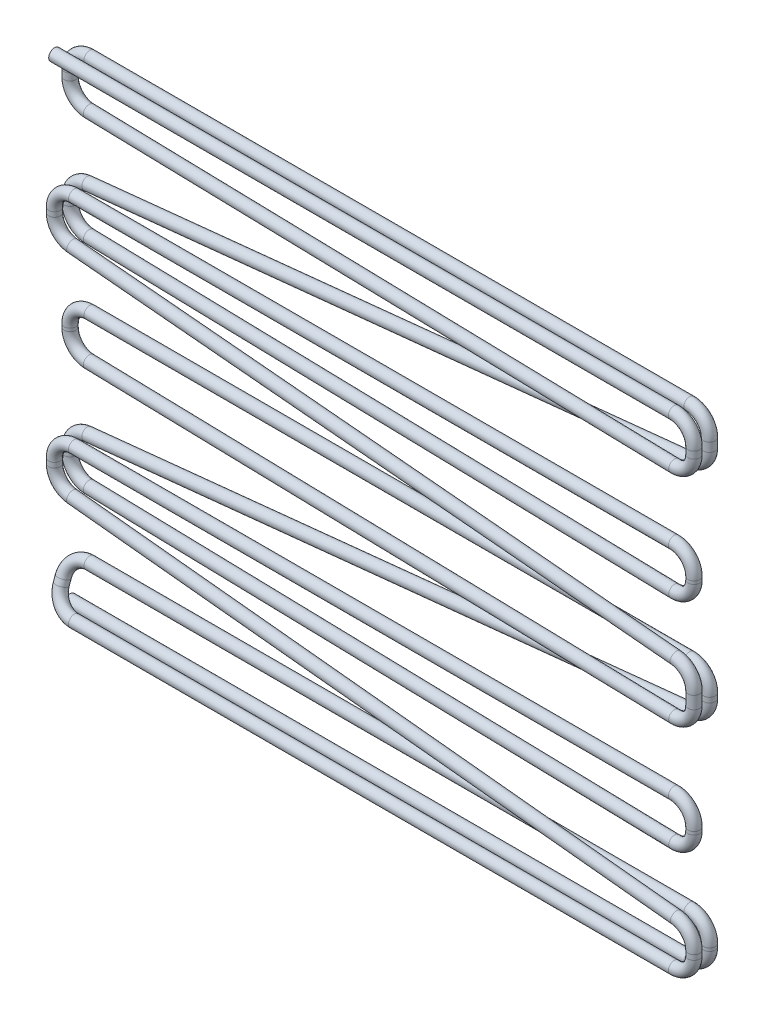
from build123d import *

# Parameters (mm, degrees)
SKETCH5_R = 0.3


with BuildPart() as part:
    # Sweep4: sweep along a curve in space
    with BuildLine() as sweep4_path:
        Line((-33, 0, 0), (-1.021255708, 0, 0))
        ThreePointArc((-1.021255708, 0, 0), (-0.299118872, 0.299118872, 0), (0, 1.021255708, 0))
        Line((0, 1.021255708, 0), (0, 1.178744292, 0))
        ThreePointArc((-1.021255708, 2.2, 0), (-0.299118872, 1.900881128, 0), (0, 1.178744292, 0))
        Line((-1.021255708, 2.2, 0), (-31.978744292, 2.2, 0))
        ThreePointArc((-31.978744292, 2.2, 0), (-32.700881128, 1.918890052, 0.102221799), (-33, 1.240230602, 0.349007054))
        Line((-33, 1.240230602, 0.349007054), (-33, 0.959769398, 0.450992946))
        ThreePointArc((-33, 0.959769398, 0.450992946), (-32.700881128, 0.281109948, 0.6977782), (-31.978744292, 0, 0.8))
        Line((-31.978744292, 0, 0.8), (-1.021255708, 0, 0.8))
        ThreePointArc((-1.021255708, 0, 0.8), (-0.299118872, 0.299118872, 0.8), (0, 1.021255708, 0.8))
        Line((0, 1.021255708, 0.8), (0, 1.278558447, 0.8))
        ThreePointArc((0, 1.278558447, 0.8), (-0.263016234, 1.962690102, 0.8), (-0.916589485, 2.294436492, 0.8))
        Line((-0.916589485, 2.294436492, 0.8), (-32.083410515, 5.505563508, 0.8))
        ThreePointArc((-33, 6.521441553, 0.8), (-32.736983766, 5.837309898, 0.8), (-32.083410515, 5.505563508, 0.8))
        Line((-33, 6.778744292, 0.8), (-33, 6.521441553, 0.8))
        ThreePointArc((-31.978744292, 7.8, 0.8), (-32.700881128, 7.500881128, 0.8), (-33, 6.778744292, 0.8))
        Line((-31.978744292, 7.8, 0.8), (-1.021255708, 7.8, 0.8))
        ThreePointArc((0, 6.778744292, 0.8), (-0.299118872, 7.500881128, 0.8), (-1.021255708, 7.8, 0.8))
        Line((0, 6.778744292, 0.8), (0, 6.621255708, 0.8))
        ThreePointArc((-1.020955747, 5.6, 0.775249557), (-0.299031015, 5.899118872, 0.792750763), (0, 6.621255708, 0.8))
        Line((-1.020955747, 5.6, 0.775249557), (-31.979044253, 5.6, 0.024750442))
        ThreePointArc((-33, 6.621255708, 0), (-32.700968985, 5.899118872, 0.007249237), (-31.979044253, 5.6, 0.024750442))
        Line((-33, 6.621255708, 0), (-33, 6.878558447, 0))
        ThreePointArc((-33, 6.878558447, 0), (-32.736983766, 7.562690102, 0), (-32.083410515, 7.894436492, 0))
        Line((-32.083410515, 7.894436492, 0), (-0.916589485, 11.105563508, 0))
        ThreePointArc((0, 12.121441553, 0), (-0.263016234, 11.437309898, 0), (-0.916589485, 11.105563508, 0))
        Line((0, 12.378744292, 0), (0, 12.121441553, 0))
        ThreePointArc((0, 12.378744292, 0), (-0.299118872, 13.100881128, 0), (-1.021255708, 13.4, 0))
        Line((-1.021255708, 13.4, 0), (-31.978744292, 13.4, 0))
        ThreePointArc((-31.978744292, 13.4, 0), (-32.700881128, 13.100881128, 0), (-33, 12.378744292, 0))
        Line((-33, 12.221255708, 0), (-33, 12.378744292, 0))
        ThreePointArc((-33, 12.221255708, 0), (-32.700968985, 11.499118872, 0.007249237), (-31.979044253, 11.2, 0.024750442))
        Line((-31.979044253, 11.2, 0.024750442), (-1.020955747, 11.2, 0.775249558))
        ThreePointArc((-1.020955747, 11.2, 0.775249558), (-0.299031015, 11.499118872, 0.792750763), (0, 12.221255708, 0.8))
        Line((0, 12.221255708, 0.8), (0, 12.867374339, 0.8))
        ThreePointArc((-0.92879556, 13.88443596, 0.8), (-0.267137456, 13.556046164, 0.8), (0, 12.867374339, 0.8))
        Line((-0.92879556, 13.88443596, 0.8), (-32.07120444, 16.71556404, 0.8))
        ThreePointArc((-32.07120444, 16.71556404, 0.8), (-32.732862544, 17.043953836, 0.8), (-33, 17.732625661, 0.8))
        Line((-33, 17.978744292, 0.8), (-33, 17.732625661, 0.8))
        ThreePointArc((-31.978744292, 19, 0.8), (-32.700881128, 18.700881128, 0.8), (-33, 17.978744292, 0.8))
        Line((-1.021255708, 19, 0.8), (-31.978744292, 19, 0.8))
        ThreePointArc((0, 17.978744292, 0.8), (-0.299118872, 18.700881128, 0.8), (-1.021255708, 19, 0.8))
        Line((0, 17.821255708, 0.8), (0, 17.978744292, 0.8))
        ThreePointArc((0, 17.821255708, 0.8), (-0.299031015, 17.099118872, 0.792750763), (-1.020955747, 16.8, 0.775249558))
        Line((-1.020955747, 16.8, 0.775249558), (-31.979044253, 16.8, 0.024750442))
        ThreePointArc((-33, 17.821255708, 0), (-32.700968985, 17.099118872, 0.007249237), (-31.979044253, 16.8, 0.024750442))
        Line((-33, 17.821255708, 0), (-33, 18.078558447, 0))
        ThreePointArc((-32.083410515, 19.094436492, 0), (-32.736983766, 18.762690102, 0), (-33, 18.078558447, 0))
        Line((-32.083410515, 19.094436492, 0), (-0.916589485, 22.305563508, 0))
        ThreePointArc((0, 23.321441553, 0), (-0.263016234, 22.637309898, 0), (-0.916589485, 22.305563508, 0))
        Line((0, 23.778744292, 0), (0, 23.321441553, 0))
        ThreePointArc((-1.021255708, 24.8, 0), (-0.299118872, 24.500881128, 0), (0, 23.778744292, 0))
        Line((-31.978744292, 24.8, 0), (-1.021255708, 24.8, 0))
        ThreePointArc((-31.978744292, 24.8, 0), (-32.700881128, 24.500881128, 0), (-33, 23.778744292, 0))
        Line((-33, 23.421255708, 0), (-33, 23.778744292, 0))
        ThreePointArc((-33, 23.421255708, 0), (-32.700968985, 22.699118872, 0.007249237), (-31.979044253, 22.4, 0.024750442))
        Line((-31.979044253, 22.4, 0.024750442), (-1.020955747, 22.4, 0.775249558))
        ThreePointArc((-1.020955747, 22.4, 0.775249558), (-0.299031015, 22.699118872, 0.792750763), (0, 23.421255708, 0.8))
        Line((0, 23.421255708, 0.8), (0, 23.778744292, 0.8))
        ThreePointArc((0, 23.778744292, 0.8), (-0.299118872, 24.500881128, 0.8), (-1.021255708, 24.8, 0.8))
        Line((-1.021255708, 24.8, 0.8), (-33, 24.8, 0.8))
    # Sketch5 → Sweep4 (sweep)
    with BuildSketch(Plane(origin=(-33, 0, 0), x_dir=(0, 0, -1), z_dir=(1, 0, 0))):
        Circle(SKETCH5_R)
    sweep(path=sweep4_path.line)


solid = part.part
